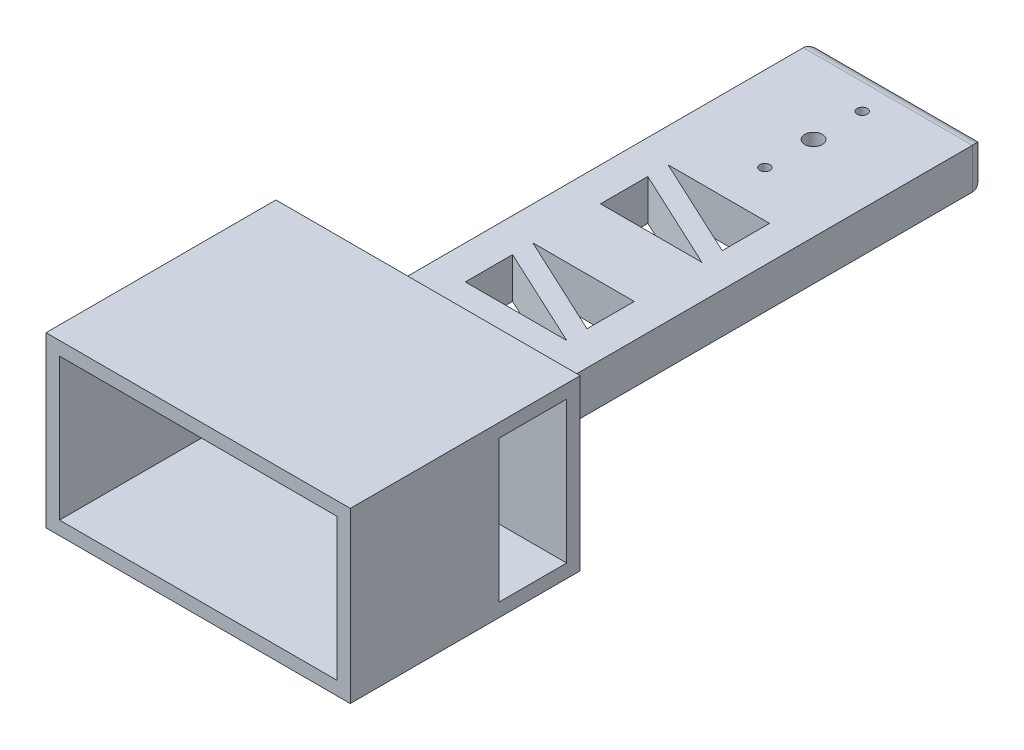
from build123d import *

# Parameters (mm, degrees)
SKETCH1_W           = 25
SKETCH1_H           = 6
BOSS_EXTRUDE1_DEPTH = 70
FILLET1_R           = 2
CUT_EXTRUDE1_DEPTH  = 6
LPATTERN1_COUNT     = 3
LPATTERN1_PITCH     = 20
SKETCH3_W           = 15
SKETCH3_H           = 9.994614872
BOSS_EXTRUDE4_DEPTH = 6
SKETCH4_W           = 45
SKETCH4_H           = 25
BOSS_EXTRUDE5_DEPTH = 2
SKETCH5_W           = 45
SKETCH5_H           = 25
SKETCH5_W_2         = 41
SKETCH5_H_2         = 21
BOSS_EXTRUDE6_DEPTH = 32
FILLET2_R           = 5
SKETCH8_W           = 10
SKETCH8_H           = 21
CUT_EXTRUDE2_DEPTH  = 45
CUT_EXTRUDE3_REACH  = 17.5
SKETCH9_R           = 1.3
SKETCH9_R_2         = 0.75


with BuildPart() as part:
    # Sketch1 → Boss-Extrude1 (new body)
    with BuildSketch(Plane.XY):
        Rectangle(SKETCH1_W, SKETCH1_H)
    extrude(amount=BOSS_EXTRUDE1_DEPTH)

    # Fillet1
    fillet1_edges = [part.edges().sort_by_distance(p)[0] for p in [
        (0, -3, 0),
        (-12.5, 0, 0),
        (0, 3, 0),
        (12.5, 0, 0),
    ]]
    fillet(fillet1_edges, radius=FILLET1_R)

    # Sketch2 → Cut-Extrude1 (cut)
    with BuildSketch(Plane(origin=(0, 3, 0), x_dir=(1, 0, 0), z_dir=(0, 1, 0))):
        Polygon((7.5, -16.994614872), (-7.5, -10), (-7.5, -16.994614872), align=None)
        Polygon((7.5, -13.994614872), (7.5, -7), (-7.5, -7), align=None)
    cut_extrude1 = extrude(amount=-CUT_EXTRUDE1_DEPTH, mode=Mode.SUBTRACT)

    # LPattern1: Cut-Extrude1 ×3
    with Locations(*[(0, 0, i * LPATTERN1_PITCH) for i in range(1, LPATTERN1_COUNT)]):
        add(cut_extrude1, mode=Mode.SUBTRACT)

    # Sketch3 → Boss-Extrude4 (add)
    with BuildSketch(Plane(origin=(0, 3, 0), x_dir=(1, 0, 0), z_dir=(0, 1, 0))):
        with Locations((0, -11.997307436)):
            Rectangle(SKETCH3_W, SKETCH3_H)
    extrude(amount=-BOSS_EXTRUDE4_DEPTH)

    # Sketch4 → Boss-Extrude5 (add)
    with BuildSketch(Plane.XY.offset(70)):
        Rectangle(SKETCH4_W, SKETCH4_H)
    extrude(amount=BOSS_EXTRUDE5_DEPTH)

    # Sketch5 → Boss-Extrude6 (add)
    with BuildSketch(Plane.XY.offset(72)):
        Rectangle(SKETCH5_W, SKETCH5_H)
        Rectangle(SKETCH5_W_2, SKETCH5_H_2, mode=Mode.SUBTRACT)
    extrude(amount=BOSS_EXTRUDE6_DEPTH)

    # Fillet2
    fillet2_edges = [part.edges().sort_by_distance(p)[0] for p in [
        (-12.5, 0, 70),
        (0, -3, 70),
        (12.5, 0, 70),
        (0, 3, 70),
    ]]
    fillet(fillet2_edges, radius=FILLET2_R)

    # Sketch8 → Cut-Extrude2 (cut)
    with BuildSketch(Plane(origin=(22.5, 0, 0), x_dir=(0, 0, -1), z_dir=(1, 0, 0))):
        with Locations((-77, 0)):
            Rectangle(SKETCH8_W, SKETCH8_H)
    extrude(amount=-CUT_EXTRUDE2_DEPTH, mode=Mode.SUBTRACT)

    # Sketch9 → Cut-Extrude3 (cut, up to next)
    with BuildSketch(Plane.XZ.offset(3), mode=Mode.PRIVATE) as cut_extrude3_sk1:
        with Locations((0, 13)):
            Circle(SKETCH9_R)
    cut_extrude3_tool1 = extrude(cut_extrude3_sk1.sketch, amount=-CUT_EXTRUDE3_REACH, mode=Mode.PRIVATE) & part.part
    add(cut_extrude3_tool1.solids().sort_by_distance((0, -3, 13))[0], mode=Mode.SUBTRACT)
    # Sketch9 → Cut-Extrude3 (cut, up to next)
    with BuildSketch(Plane.XZ.offset(3), mode=Mode.PRIVATE) as cut_extrude3_sk2:
        with Locations((0, 20.2)):
            Circle(SKETCH9_R_2)
    cut_extrude3_tool2 = extrude(cut_extrude3_sk2.sketch, amount=-CUT_EXTRUDE3_REACH, mode=Mode.PRIVATE) & part.part
    add(cut_extrude3_tool2.solids().sort_by_distance((0, -3, 20.2))[0], mode=Mode.SUBTRACT)
    # Sketch9 → Cut-Extrude3 (cut, up to next)
    with BuildSketch(Plane.XZ.offset(3), mode=Mode.PRIVATE) as cut_extrude3_sk3:
        with Locations((0, 5.8)):
            Circle(SKETCH9_R_2)
    cut_extrude3_tool3 = extrude(cut_extrude3_sk3.sketch, amount=-CUT_EXTRUDE3_REACH, mode=Mode.PRIVATE) & part.part
    add(cut_extrude3_tool3.solids().sort_by_distance((0, -3, 5.8))[0], mode=Mode.SUBTRACT)


solid = part.part
